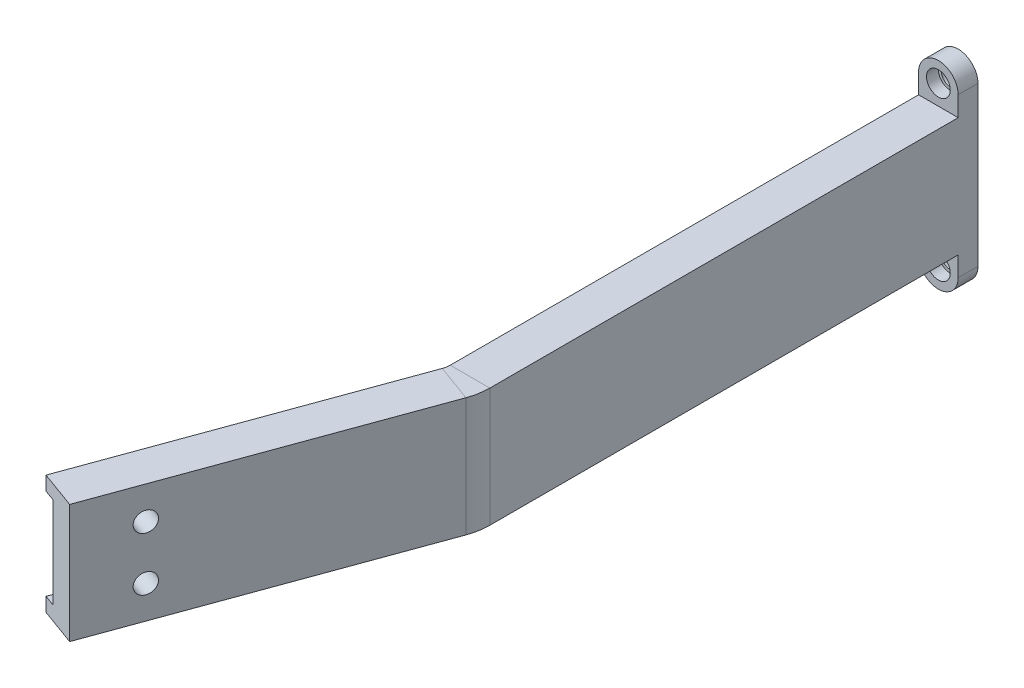
from build123d import *

# Parameters (mm, degrees)
SKETCH_1_R                = 115
SKETCH_1_R_2              = 105
EXTRUDE_1_DEPTH           = 5
SKETCH_4_R                = 2.5
CUT_EXTRUDE_1_DEPTH       = 33.934862746
EXTRUDE_2_DEPTH           = 5
HOLE_WIZARD_1_D           = 4.5
HOLE_WIZARD_1_CBORE_D     = 6
HOLE_WIZARD_1_CBORE_DEPTH = 3
SKETCH_9_R                = 2.25
SKETCH_9_R_2              = 1.9
EXTRUDE_3_DEPTH           = 5
EXTRUDE_4_DEPTH           = 5
HOLE_WIZARD_2_D           = 4.5
HOLE_WIZARD_2_CBORE_D     = 6
HOLE_WIZARD_2_CBORE_DEPTH = 3
SKETCH_13_R               = 2.25
SKETCH_13_R_2             = 1.9
EXTRUDE_5_DEPTH           = 5
SKETCH_14_W               = 562.038590931
SKETCH_14_H               = 462.09177453
CUT_EXTRUDE_4_DEPTH       = 163.29776757
SKETCH_15_W               = 480.927145246
SKETCH_15_H               = 274.608213656
CUT_EXTRUDE_5_DEPTH       = 161


with BuildPart() as part:
    # 草图1 → 凸台-拉伸1 (new body, symmetric)
    with BuildSketch(Plane.XY):
        Circle(SKETCH_1_R)
        Circle(SKETCH_1_R_2, mode=Mode.SUBTRACT)
    extrude(amount=EXTRUDE_1_DEPTH, both=True)

    # 扫描1: sweep along a path in 草图2
    with BuildLine(Plane(origin=(0, 0, 0), x_dir=(1, 0, 0), z_dir=(0, 1, 0))) as sweep_1_path:
        Line((-130, -355), (-156.694693778, -281.656931626))
        ThreePointArc((-156.694693778, -281.656931626), (-157.1458451, -279.97321197), (-157.29776757, -278.236730193))
        Line((-157.29776757, -278.236730193), (-157.29776757, -10))
        ThreePointArc((-157.29776757, -10), (-154.368835382, -2.928932188), (-147.29776757, 0))
        Line((-147.29776757, 0), (-115, 0))
        Line((-115, 0), (-106.681302201, 0))
    # 草图3 → 扫描1 (sweep)
    with BuildSketch(Plane(origin=(-130, 0, 355), x_dir=(0.939692621, 0, -0.342020143), z_dir=(0.342020143, 0, 0.939692621))):
        Polygon((-5, -15), (5, -15), (5, -11.5), (2, -11.5), (2, 11.5), (5, 11.5), (5, 15), (-5, 15), align=None)
    sweep_1 = sweep(path=sweep_1_path.line)

    # 草图4 → 切除-拉伸1 (cut, through all)
    with BuildSketch(Plane(origin=(-227.008304281, 0, 82.624265689), x_dir=(-0.342020143, 0, -0.939692621), z_dir=(0.939692621, 0, -0.342020143))):
        with Locations((-274.128261747, 6.75)):
            Circle(SKETCH_4_R)
        with Locations((-274.128261747, -6.75)):
            Circle(SKETCH_4_R)
    cut_extrude_1 = extrude(amount=-CUT_EXTRUDE_1_DEPTH, mode=Mode.SUBTRACT)

    # 镜向1: 扫描1, 切除-拉伸1 across plane
    add(sweep_1.mirror(Plane(origin=(0, 0, 0), x_dir=(0, 0, 1), z_dir=(1, 0, 0))))
    add(cut_extrude_1.mirror(Plane(origin=(0, 0, 0), x_dir=(0, 0, 1), z_dir=(1, 0, 0))), mode=Mode.SUBTRACT)

    # 草图6 → 凸台-拉伸2 (add, symmetric)
    with BuildSketch(Plane(origin=(0, 0, 0), x_dir=(0, 0, -1), z_dir=(1, 0, 0))):
        with BuildLine():
            Line((-5, 115), (-5, 125))
            ThreePointArc((-5, 125), (0, 130), (5, 125))
            Line((5, 125), (5, 115))
            Line((5, 115), (5, 112.136445143))
            Line((5, 112.136445143), (-5, 112.136445143))
            Line((-5, 112.136445143), (-5, 115))
        make_face()
    extrude_2 = extrude(amount=EXTRUDE_2_DEPTH, both=True)

    # 镜向2: 凸台-拉伸2 across plane
    add(extrude_2.mirror(Plane.ZX))

    # 孔1 (through all)
    with Locations(Plane(origin=(5, 0, 0), x_dir=(0, 0, -1), z_dir=(1, 0, 0))):
        with Locations((0, 124.156343107), (0, -125)):
            CounterBoreHole(HOLE_WIZARD_1_D / 2, HOLE_WIZARD_1_CBORE_D / 2, HOLE_WIZARD_1_CBORE_DEPTH)

    # 草图9 → 凸台-拉伸3 (add)
    with BuildSketch(Plane.ZY.offset(5)):
        with Locations((0, 124.156343107)):
            Circle(SKETCH_9_R)
        with Locations((0, 124.156343107)):
            Circle(SKETCH_9_R_2, mode=Mode.SUBTRACT)
        with Locations((0, -125)):
            Circle(SKETCH_9_R)
        with Locations((0, -125)):
            Circle(SKETCH_9_R_2, mode=Mode.SUBTRACT)
    extrude(amount=-EXTRUDE_3_DEPTH)

    # 草图10 → 凸台-拉伸4 (add, symmetric)
    with BuildSketch(Plane.XY.offset(155)):
        with BuildLine():
            Line((-162.29776757, 15), (-152.29776757, 15))
            Line((-152.29776757, 15), (-152.29776757, 20))
            ThreePointArc((-152.29776757, 20), (-157.29776757, 25), (-162.29776757, 20))
            Line((-162.29776757, 20), (-162.29776757, 15))
        make_face()
        with BuildLine():
            Line((-152.29776757, -15), (-152.29776757, -20))
            ThreePointArc((-152.29776757, -20), (-157.29776757, -25), (-162.29776757, -20))
            Line((-162.29776757, -20), (-162.29776757, -15))
            Line((-162.29776757, -15), (-152.29776757, -15))
        make_face()
        with BuildLine():
            Line((162.29776757, -15), (152.29776757, -15))
            Line((152.29776757, -15), (152.29776757, -20))
            ThreePointArc((152.29776757, -20), (157.29776757, -25), (162.29776757, -20))
            Line((162.29776757, -20), (162.29776757, -15))
        make_face()
        with BuildLine():
            Line((152.29776757, 15), (152.29776757, 20))
            ThreePointArc((152.29776757, 20), (157.29776757, 25), (162.29776757, 20))
            Line((162.29776757, 20), (162.29776757, 15))
            Line((162.29776757, 15), (152.29776757, 15))
        make_face()
    extrude(amount=EXTRUDE_4_DEPTH, both=True)

    # 孔2 (through all)
    with Locations(Plane.XY.offset(160)):
        with Locations((-157.29776757, 20), (-157.29776757, -20), (157.29776757, 20), (157.29776757, -20)):
            CounterBoreHole(HOLE_WIZARD_2_D / 2, HOLE_WIZARD_2_CBORE_D / 2, HOLE_WIZARD_2_CBORE_DEPTH)

    # 草图13 → 凸台-拉伸5 (add)
    with BuildSketch(Plane(origin=(0, 0, 150), x_dir=(-1, 0, 0), z_dir=(0, 0, -1))):
        with Locations((-157.29776757, 20)):
            Circle(SKETCH_13_R)
        with Locations((-157.29776757, 20)):
            Circle(SKETCH_13_R_2, mode=Mode.SUBTRACT)
        with Locations((-157.29776757, -20)):
            Circle(SKETCH_13_R)
        with Locations((-157.29776757, -20)):
            Circle(SKETCH_13_R_2, mode=Mode.SUBTRACT)
        with Locations((157.29776757, -20)):
            Circle(SKETCH_13_R)
        with Locations((157.29776757, -20)):
            Circle(SKETCH_13_R_2, mode=Mode.SUBTRACT)
        with Locations((157.29776757, 20)):
            Circle(SKETCH_13_R)
        with Locations((157.29776757, 20)):
            Circle(SKETCH_13_R_2, mode=Mode.SUBTRACT)
    extrude(amount=-EXTRUDE_5_DEPTH)

    # 草图14 → 切除-拉伸4 (cut, through all)
    with BuildSketch(Plane(origin=(0, 0, 0), x_dir=(0, 0, -1), z_dir=(1, 0, 0))):
        with Locations((-153.139864812, -31.152254463)):
            Rectangle(SKETCH_14_W, SKETCH_14_H)
    extrude(amount=-CUT_EXTRUDE_4_DEPTH, mode=Mode.SUBTRACT)

    # 草图15 → 切除-拉伸5 (cut, through all)
    with BuildSketch(Plane.XY.offset(155)):
        Rectangle(SKETCH_15_W, SKETCH_15_H)
    extrude(amount=-CUT_EXTRUDE_5_DEPTH, mode=Mode.SUBTRACT)


solid = part.part
